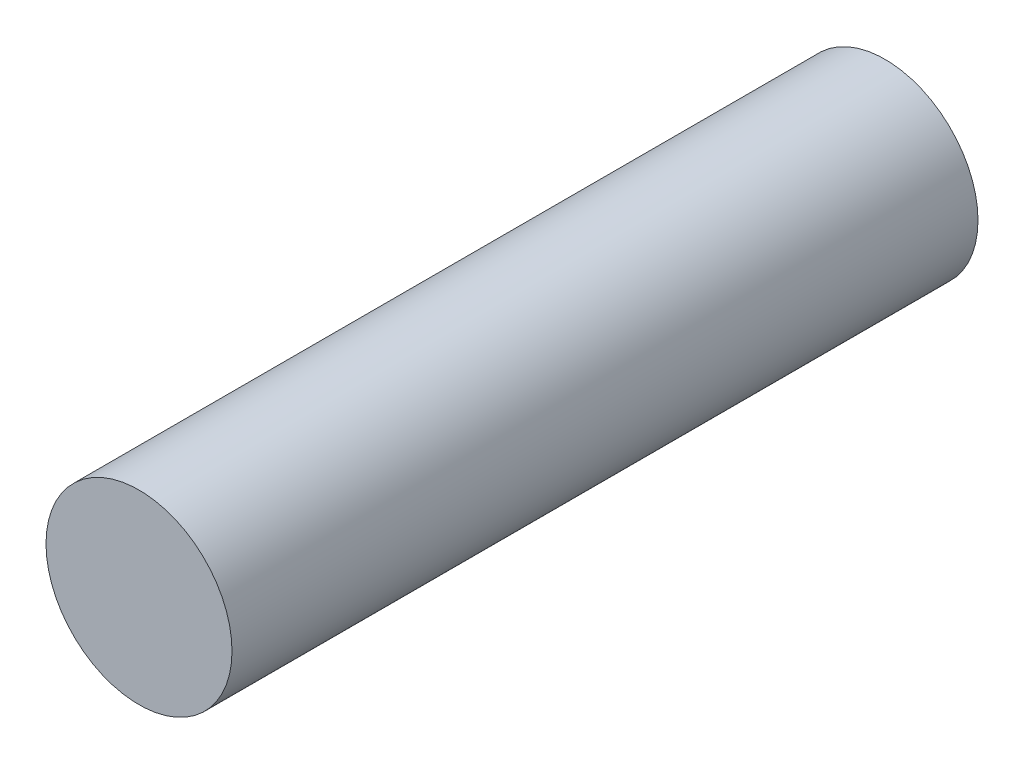
from build123d import *

# Parameters (mm, degrees)
SKETCH1_R           = 2.3749
BOSS_EXTRUDE1_DEPTH = 19.05


with BuildPart() as part:
    # Sketch1 → Boss-Extrude1 (new body)
    with BuildSketch(Plane.XY):
        Circle(SKETCH1_R)
    extrude(amount=-BOSS_EXTRUDE1_DEPTH)


solid = part.part
